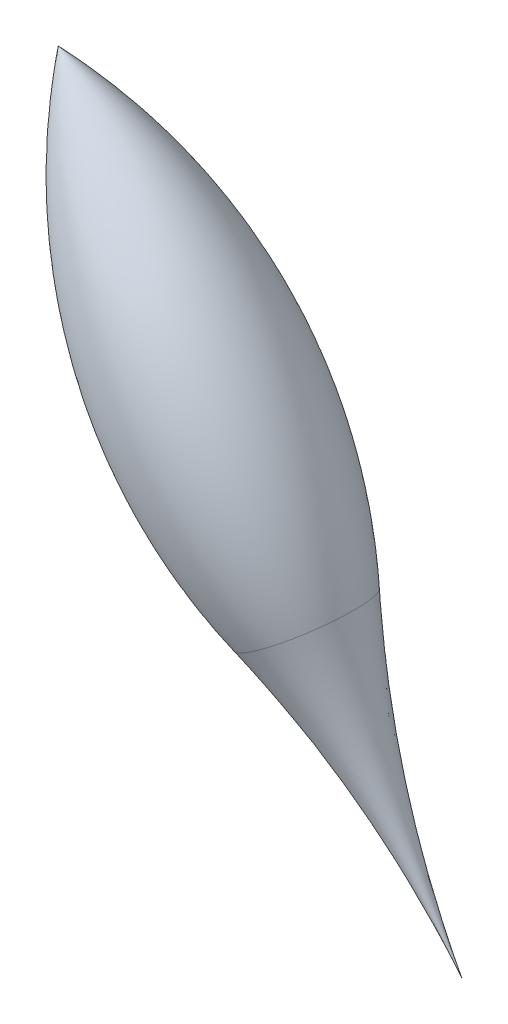
from build123d import *


with BuildPart() as part:
    # Sketch2 → Revolve2 (revolve)
    with BuildSketch(Plane.XY):
        with BuildLine():
            Line((-50, 75), (50, -75))
            ThreePointArc((50, -75), (26.776695297, -48.223304703), (0, -25))
            ThreePointArc((0, -25), (-36.803398875, 19.098300563), (-50, 75))
        make_face()
    revolve(axis=Axis((-50, 75, 0), (0.554700196, -0.832050294, 0)))


solid = part.part
